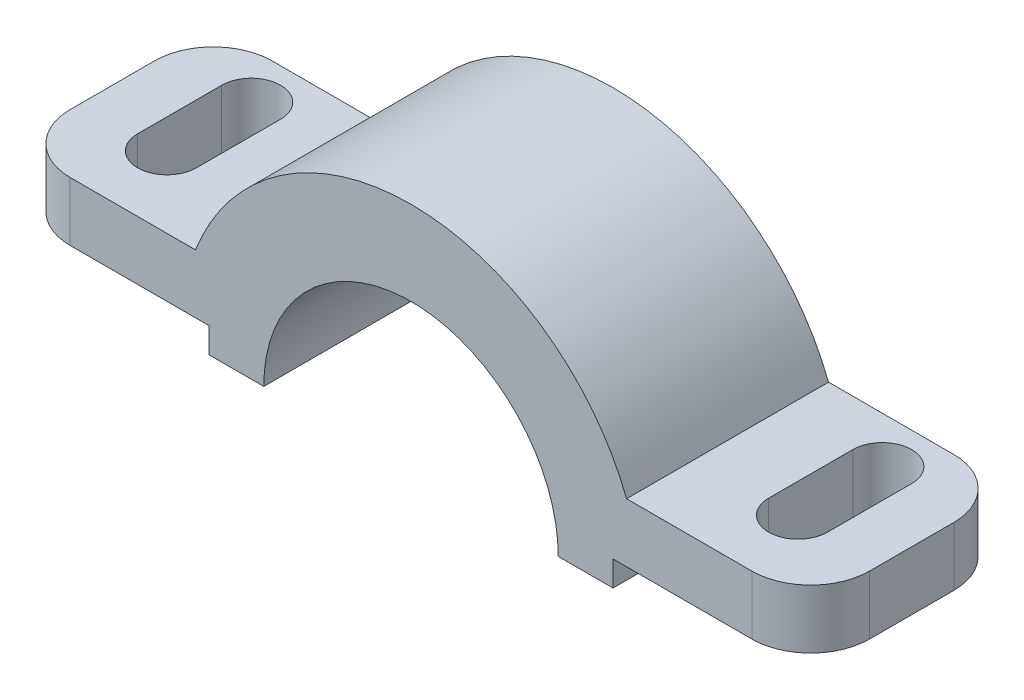
from build123d import *

# Parameters (mm, degrees)
BOSS_EXTRUDE1_DEPTH     = 24
FILLET1_R               = 14
CUT_EXTRUDE1_DEPTH      = 36
CUT_EXTRUDE1_DEPTH_BACK = 21


with BuildPart() as part:
    # Sketch1 → Boss-Extrude1 (new body, symmetric)
    with BuildSketch(Plane.XY):
        with BuildLine():
            Line((35, 0), (48, 0))
            Line((48, 0), (48, 6))
            Line((48, 6), (95, 6))
            Line((95, 6), (95, 20))
            Line((95, 20), (51.23475383, 20))
            ThreePointArc((51.23475383, 20), (0, 55), (-51.23475383, 20))
            Line((-51.23475383, 20), (-95, 20))
            Line((-95, 20), (-95, 6))
            Line((-95, 6), (-48, 6))
            Line((-48, 6), (-48, 0))
            Line((-48, 0), (-35, 0))
            ThreePointArc((-35, 0), (0, 35), (35, 0))
        make_face()
    extrude(amount=BOSS_EXTRUDE1_DEPTH, both=True)

    # Fillet1
    fillet1_edges = [part.edges().sort_by_distance(p)[0] for p in [
        (95, 13, -24),
        (-95, 13, -24),
        (95, 13, 24),
        (-95, 13, 24),
    ]]
    fillet(fillet1_edges, radius=FILLET1_R)

    # Sketch2 → Cut-Extrude1 (cut, two sides)
    with BuildSketch(Plane(origin=(0, 20, 0), x_dir=(1, 0, 0), z_dir=(0, 1, 0))) as cut_extrude1_sk:
        with BuildLine():
            Line((68, -7), (68, 13))
            ThreePointArc((68, 13), (75, 20), (82, 13))
            Line((82, 13), (82, -7))
            ThreePointArc((82, -7), (75, -14), (68, -7))
        make_face()
        with BuildLine():
            Line((-68, -7), (-68, 13))
            ThreePointArc((-68, 13), (-75, 20), (-82, 13))
            Line((-82, 13), (-82, -7))
            ThreePointArc((-82, -7), (-75, -14), (-68, -7))
        make_face()
    extrude(amount=CUT_EXTRUDE1_DEPTH, mode=Mode.SUBTRACT)
    extrude(cut_extrude1_sk.sketch, amount=-CUT_EXTRUDE1_DEPTH_BACK, mode=Mode.SUBTRACT)


solid = part.part
